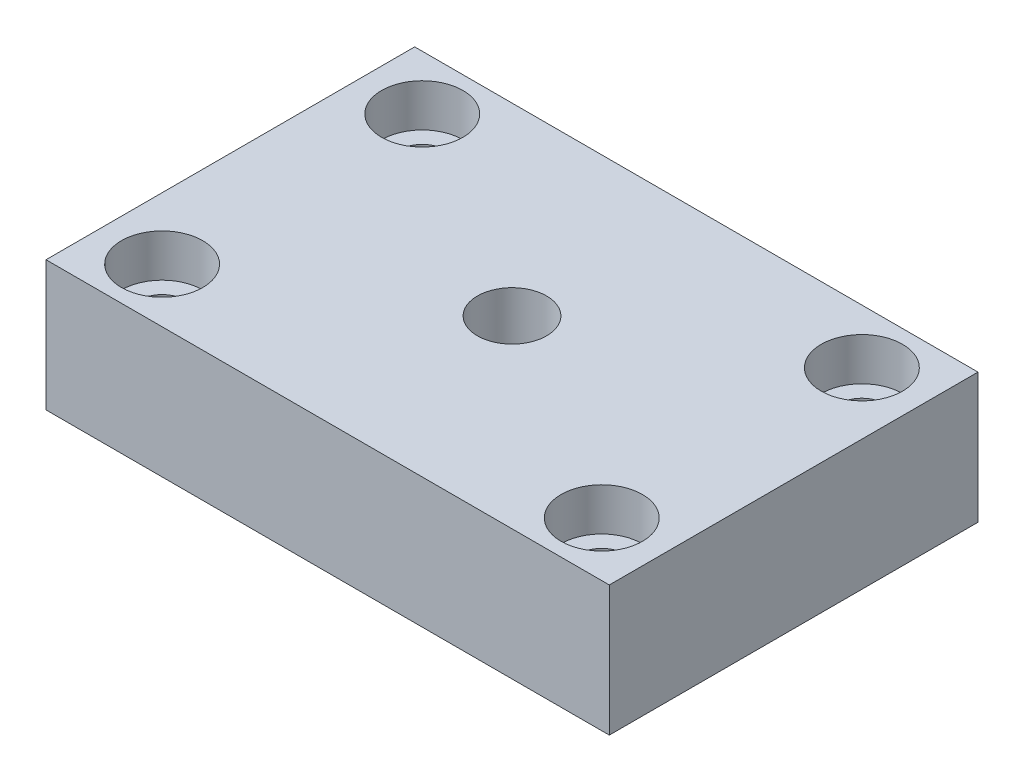
from build123d import *

# Parameters (mm, degrees)
SKETCH1_W                                        = 55
SKETCH1_H                                        = 36
BOSS_EXTRUDE1_DEPTH                              = 12.7
CBORE_FOR_8_SOCKET_HEAD_CAP_SCREW1_D             = 4.4958
CBORE_FOR_8_SOCKET_HEAD_CAP_SCREW1_CBORE_D       = 7.9375
CBORE_FOR_8_SOCKET_HEAD_CAP_SCREW1_CBORE_DEPTH   = 4.1656
CBORE_FOR_1_4_SOCKET_HEAD_CAP_SCREW1_D           = 6.7564
CBORE_FOR_1_4_SOCKET_HEAD_CAP_SCREW1_CBORE_D     = 11.1125
CBORE_FOR_1_4_SOCKET_HEAD_CAP_SCREW1_CBORE_DEPTH = 6.35


with BuildPart() as part:
    # Sketch1 → Boss-Extrude1 (new body)
    with BuildSketch(Plane(origin=(0, 0, 0), x_dir=(1, 0, 0), z_dir=(0, 1, 0))):
        Rectangle(SKETCH1_W, SKETCH1_H)
    extrude(amount=BOSS_EXTRUDE1_DEPTH)

    # CBORE for #8 Socket Head Cap Screw1 (through all)
    with Locations(Plane(origin=(0, 12.7, 0), x_dir=(-1, 0, 0), z_dir=(0, 1, 0))):
        with Locations((21.463, -12.7), (21.463, 12.7), (-21.463, 12.7), (-21.463, -12.7)):
            CounterBoreHole(CBORE_FOR_8_SOCKET_HEAD_CAP_SCREW1_D / 2, CBORE_FOR_8_SOCKET_HEAD_CAP_SCREW1_CBORE_D / 2, CBORE_FOR_8_SOCKET_HEAD_CAP_SCREW1_CBORE_DEPTH)

    # CBORE for 1/4 Socket Head Cap Screw1 (through all)
    with Locations(Plane(origin=(0, 0, 0), x_dir=(-1, 0, 0), z_dir=(0, -1, 0))):
        with Locations((0, 0)):
            CounterBoreHole(CBORE_FOR_1_4_SOCKET_HEAD_CAP_SCREW1_D / 2, CBORE_FOR_1_4_SOCKET_HEAD_CAP_SCREW1_CBORE_D / 2, CBORE_FOR_1_4_SOCKET_HEAD_CAP_SCREW1_CBORE_DEPTH)


solid = part.part
